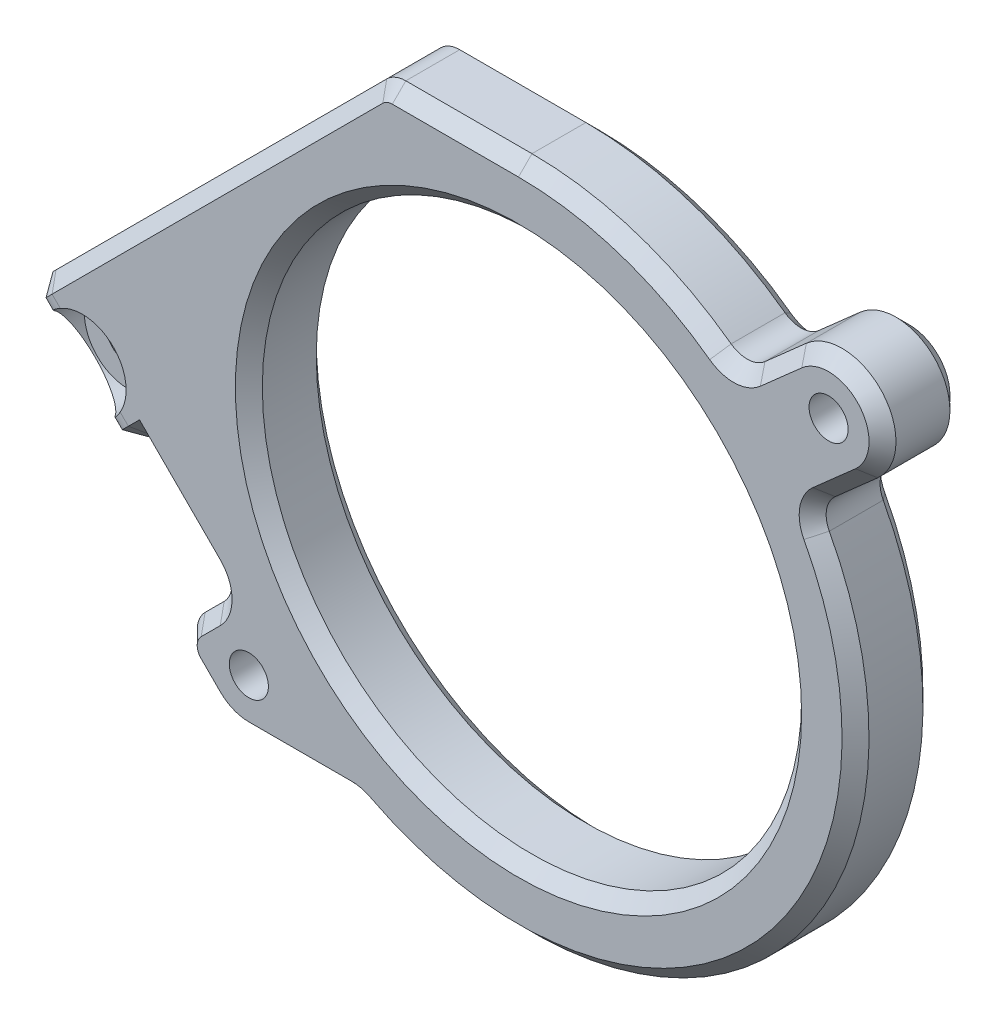
from build123d import *

# Parameters (mm, degrees)
SKETCH_1_W                   = 60
SKETCH_1_H                   = 55
EXTRUDE_1_DEPTH              = 6
HOLE_WIZARD_M4_1_D           = 2.9
HOLE_WIZARD_M4_1_DEPTH       = 10
SKETCH_5_R                   = 20
CUT_EXTRUDE_1_DEPTH          = 7
SKETCH_6_W                   = 60
SKETCH_6_H                   = 55
CUT_EXTRUDE_2_DEPTH          = 7
EXTRUDE_2_DEPTH              = 6
EXTRUDE_3_DEPTH              = 6
EXTRUDE_4_DEPTH              = 4
CUT_EXTRUDE_3_DEPTH          = 11
CUT_EXTRUDE_4_DEPTH          = 6
FILLET_1_R                   = 2
EXTRUDE_5_DEPTH              = 6
CHAMFER_2_SIZE               = 5
FILLET_4_R                   = 2
CHAMFER_3_SIZE               = 1
HOLE_WIZARD_M3_2_D           = 3.3
HOLE_WIZARD_M3_2_DEPTH       = 10
HOLE_WIZARD_M3_2_CBORE_D     = 6.5
HOLE_WIZARD_M3_2_CBORE_DEPTH = 3.4
HOLE_WIZARD_M3_2_TIP         = 0.991420021


with BuildPart() as part:
    # ｽｹｯﾁ1 → ﾎﾞｽ - 押し出し1 (new body)
    with BuildSketch(Plane.XY):
        Rectangle(SKETCH_1_W, SKETCH_1_H)
    extrude(amount=EXTRUDE_1_DEPTH)

    # M4 すきま穴1
    with Locations(Plane.XY.offset(6)):
        with Locations((-20, -18), (23, 20)):
            Hole(HOLE_WIZARD_M4_1_D / 2, depth=HOLE_WIZARD_M4_1_DEPTH)

    # ｽｹｯﾁ5 → ｶｯﾄ - 押し出し1 (cut, through all)
    with BuildSketch(Plane.XY.offset(6)):
        Circle(SKETCH_5_R)
    extrude(amount=-CUT_EXTRUDE_1_DEPTH, mode=Mode.SUBTRACT)

    # ｽｹｯﾁ6 → ｶｯﾄ - 押し出し2 (cut, through all)
    with BuildSketch(Plane.XY.offset(6)):
        Rectangle(SKETCH_6_W, SKETCH_6_H)
        with BuildLine():
            ThreePointArc((-17.351208814, -20.997316342), (-22.997316342, -20.648791186), (-22.648791186, -15.002683658))
            Line((-22.648791186, -15.002683658), (-21.007829355, -13.552531342))
            ThreePointArc((-21.007829355, -13.552531342), (-16.554944912, 18.733227137), (16.03335661, 19.181539975))
            Line((16.03335661, 19.181539975), (20.351208814, 22.997316342))
            ThreePointArc((20.351208814, 22.997316342), (25.997316342, 22.648791186), (25.648791186, 17.002683658))
            Line((25.648791186, 17.002683658), (21.271672672, 13.134532414))
            ThreePointArc((21.271672672, 13.134532414), (24.04986296, 6.826718948), (25, 0))
            ThreePointArc((25, 0), (10.810307191, -22.541900062), (-15.650980674, -19.494789148))
            Line((-15.650980674, -19.494789148), (-17.351208814, -20.997316342))
        make_face(mode=Mode.SUBTRACT)
    extrude(amount=-CUT_EXTRUDE_2_DEPTH, mode=Mode.SUBTRACT)

    # ｽｹｯﾁ7 → ﾎﾞｽ - 押し出し2 (add)
    with BuildSketch(Plane.XY.offset(6)):
        with BuildLine():
            Line((0, 25), (-21.5, 25))
            Line((-21.5, 25), (-21.5, 12.757350822))
            ThreePointArc((-21.5, 12.757350822), (-12.370655388, 21.724798855), (0, 25))
        make_face()
        with BuildLine():
            ThreePointArc((-17.351208814, -20.997316342), (-18.583890076, -21.74094008), (-20, -22))
            Line((-20, -22), (-11.874342087, -22))
            ThreePointArc((-11.874342087, -22), (-13.819546614, -20.833149819), (-15.650980674, -19.494789148))
            Line((-15.650980674, -19.494789148), (-17.351208814, -20.997316342))
        make_face()
        with BuildLine():
            ThreePointArc((-21.007829355, -13.552531342), (-21.25763315, -13.157242601), (-21.5, -12.757350822))
            Line((-21.5, -12.757350822), (-21.5, -13.987472843))
            Line((-21.5, -13.987472843), (-21.007829355, -13.552531342))
        make_face()
    extrude(amount=-EXTRUDE_2_DEPTH)

    # ｽｹｯﾁ8 → ﾎﾞｽ - 押し出し3 (add)
    with BuildSketch(Plane.XY.offset(6)):
        with BuildLine():
            Line((-21.5, 12.757350822), (-21.5, 25))
            Line((-21.5, 25), (-45.078427125, 1.421572875))
            Line((-45.078427125, 1.421572875), (-22.82842714, -20.828427109))
            ThreePointArc((-22.82842714, -20.828427109), (-23.998099778, -17.876719173), (-22.648791186, -15.002683658))
            Line((-22.648791186, -15.002683658), (-21.5, -13.987472843))
            Line((-21.5, -13.987472843), (-21.5, -12.757350822))
            ThreePointArc((-21.5, -12.757350822), (-25, 0), (-21.5, 12.757350822))
        make_face()
    extrude(amount=-EXTRUDE_3_DEPTH)

    # ｽｹｯﾁ9 → ﾎﾞｽ - 押し出し4 (add)
    with BuildSketch(Plane(origin=(0, 0, 0), x_dir=(-1, 0, 0), z_dir=(0, 0, -1))):
        Polygon((25.279437252, -4.235281374), (32.350505063, -11.306349186), (45.078427125, 1.421572875), (38.007359313, 8.492640687), align=None)
    extrude(amount=EXTRUDE_4_DEPTH)

    # ｽｹｯﾁ10 → ｶｯﾄ - 押し出し3 (cut, through all)
    with BuildSketch(Plane(origin=(0, 0, -4), x_dir=(-1, 0, 0), z_dir=(0, 0, -1))):
        Polygon((38.007359313, 8.492640687), (21.5, 25), (10.186291501, 25), (39.421572875, -4.235281374), (45.078427125, 1.421572875), align=None)
    extrude(amount=-CUT_EXTRUDE_3_DEPTH, mode=Mode.SUBTRACT)

    # ｽｹｯﾁ12 → ｶｯﾄ - 押し出し4 (cut)
    with BuildSketch(Plane.XY.offset(6)):
        Polygon((-39.421572875, -4.235281374), (-25.656854249, -18), (-21.414213562, -13.757359313), (-35.178932188, 0.007359313), align=None)
    extrude(amount=-CUT_EXTRUDE_4_DEPTH, mode=Mode.SUBTRACT)

    # ﾌｨﾚｯﾄ1
    fillet_1_edges = [part.edges().sort_by_distance(p)[0] for p in [
        (-25.279437252, -4.235281374, -2),
        (-32.350505063, 2.835786438, -2),
        (-25.656854249, -18, 3),
    ]]
    fillet(fillet_1_edges, radius=FILLET_1_R)

    # ｽｹｯﾁ13 → ﾎﾞｽ - 押し出し5 (add)
    with BuildSketch(Plane.XY):
        Polygon((-32.350505063, -11.306349186), (-28.107864376, -7.063708499), (-35.178932188, 0.007359313), (-39.421572875, -4.235281374), align=None)
    extrude(amount=EXTRUDE_5_DEPTH)

    # 面取り2
    chamfer_2_edges = [part.edges().sort_by_distance(p)[0] for p in [
        (-35.886038969, -7.77081528, 6),
    ]]
    chamfer(chamfer_2_edges, length=CHAMFER_2_SIZE)

    # ﾌｨﾚｯﾄ4
    fillet_4_edges = [part.edges().sort_by_distance(p)[0] for p in [
        (-10.186291501, 25, 3),
        (-21.414213562, -13.757359313, 3),
        (-32.350505063, -4.235281374, 6),
        (-35.886038969, -7.77081528, 1),
        (21.271672672, 13.134532414, 3),
        (16.03335661, 19.181539975, 3),
        (-11.874342087, -22, 3),
    ]]
    fillet(fillet_4_edges, radius=FILLET_4_R)

    # 面取り3
    chamfer_3_edges = [part.edges().sort_by_distance(p)[0] for p in [
        (-21.53073374, -21.695518126, 6),
        (-21.53073374, -21.695518126, 0),
        (-23.535533914, -20.121320336, 0),
        (-29.522077939, -8.477922061, -4),
        (-32.350505063, -11.306349186, -1.914213562),
        (-35.886038969, -7.77081528, -4),
        (-36.593145751, -1.406854249, -4),
        (-28.814971157, -0.699747468, -4),
        (-32.350505063, 2.007359313, -4),
        (-26.107864376, -4.235281374, -4),
        (-23.535533906, -15.878679656, 6),
        (-23.535533906, -15.878679656, 0),
        (-23.535533914, -20.121320336, 6),
        (-24.828427125, -18, 6),
        (-24.828427125, -18, 0),
        (24.071292776, 15.608615296, 6),
        (24.071292776, 15.608615296, 0),
        (17.805324329, -17.549086174, 0),
        (17.805324329, -17.549086174, 6),
        (7.771710455, 23.761323966, 6),
        (7.771710455, 23.761323966, 0),
        (18.815379015, 21.640071403, 6),
        (18.815379015, 21.640071403, 0),
        (-39.421572875, -4.235281374, -1.914213562),
        (-37.653805922, -2.467514421, 3.5),
        (-23.036165235, 12.150126266, 6),
        (-22.268398282, 12.917893219, 0),
        (-35.841448632, -0.655157131, 5.847759065),
        (-39.313922278, -4.127630777, 0.93693974),
        (-25.468145751, -9.703427125, 0),
        (-4.678932188, 25, 0),
        (-16.184658438, -22, 0),
        (-10.123231241, 24.847759065, 0),
        (-28.168524548, -7.124368671, 6),
        (-25.468145751, -9.703427125, 6),
        (-10.123231241, 24.847759065, 6),
        (-30.58273811, -9.538582233, 3.5),
        (-28.77038082, -7.726224943, 5.847759065),
        (-32.242854466, -11.198698589, 0.93693974),
        (21.8499093, 13.07067214, 0),
        (21.8499093, 13.07067214, 6),
        (16.046656493, 19.783578925, 0),
        (16.046656493, 19.783578925, 6),
        (-11.897912356, -22.056349368, 6),
        (-11.897912356, -22.056349368, 0),
        (-22.242640687, -13.757359313, 6),
        (-22.242640687, -13.757359313, 0),
        (-20, 0, 0),
        (-20, 0, 6),
        (25.997316342, 22.648791186, 0),
        (25.997316342, 22.648791186, 6),
        (-16.184658438, -22, 6),
        (-4.678932188, 25, 6),
    ]]
    chamfer(chamfer_3_edges, length=CHAMFER_3_SIZE)

    # M3 六角穴付き頭ねじ用座ぐり穴2
    with Locations(Plane.XY.offset(6)):
        with Locations((-32.350505063, -4.235281374)):
            CounterBoreHole(HOLE_WIZARD_M3_2_D / 2, HOLE_WIZARD_M3_2_CBORE_D / 2, HOLE_WIZARD_M3_2_CBORE_DEPTH, depth=HOLE_WIZARD_M3_2_DEPTH)
            with Locations((0, 0, -(HOLE_WIZARD_M3_2_DEPTH + HOLE_WIZARD_M3_2_TIP / 2))):  # 118° drill point
                Cone(0, HOLE_WIZARD_M3_2_D / 2, HOLE_WIZARD_M3_2_TIP, mode=Mode.SUBTRACT)


solid = part.part
